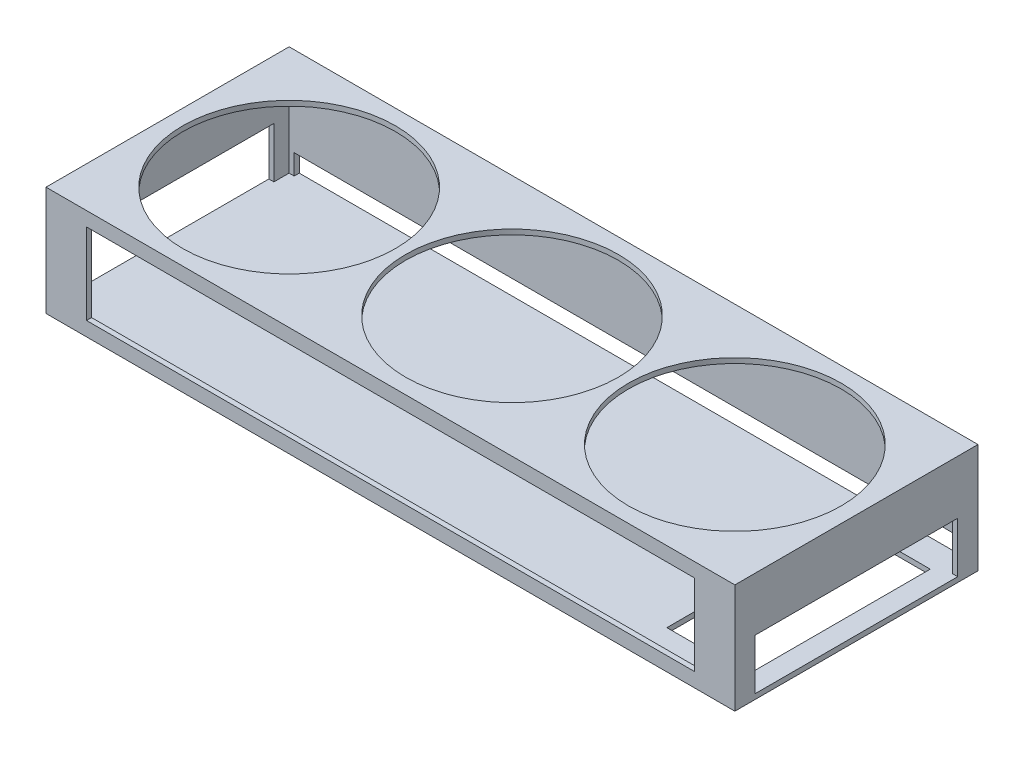
from build123d import *

# Parameters (mm, degrees)
SKETCH1_W           = 340
SKETCH1_H           = 54
BOSS_EXTRUDE1_DEPTH = 120
SHELL1_T            = 2.5
SKETCH2_R           = 52.5
CUT_EXTRUDE1_DEPTH  = 10
SKETCH3_W           = 300
SKETCH3_H           = 40
CUT_EXTRUDE2_DEPTH  = 10
SKETCH4_W           = 100
SKETCH4_H           = 25
CUT_EXTRUDE3_DEPTH  = 341
SKETCH5_W           = 40
SKETCH5_H           = 90
CUT_EXTRUDE4_DEPTH  = 10
SKETCH6_W           = 330
SKETCH6_H           = 10
CUT_EXTRUDE5_DEPTH  = 10


with BuildPart() as part:
    # Sketch1 → Boss-Extrude1 (new body)
    with BuildSketch(Plane.XY):
        Rectangle(SKETCH1_W, SKETCH1_H)
    extrude(amount=BOSS_EXTRUDE1_DEPTH)

    # Shell1 (no face opened: a closed hollow body)
    add(offset(amount=-SHELL1_T, mode=Mode.PRIVATE), mode=Mode.SUBTRACT)

    # Sketch2 → Cut-Extrude1 (cut)
    with BuildSketch(Plane(origin=(0, 27, 0), x_dir=(1, 0, 0), z_dir=(0, 1, 0))):
        with Locations((-110, -60)):
            Circle(SKETCH2_R)
        with Locations((0, -60)):
            Circle(SKETCH2_R)
        with Locations((110, -60)):
            Circle(SKETCH2_R)
    extrude(amount=-CUT_EXTRUDE1_DEPTH, mode=Mode.SUBTRACT)

    # Sketch3 → Cut-Extrude2 (cut)
    with BuildSketch(Plane.XY.offset(120)):
        Rectangle(SKETCH3_W, SKETCH3_H)
    extrude(amount=-CUT_EXTRUDE2_DEPTH, mode=Mode.SUBTRACT)

    # Sketch4 → Cut-Extrude3 (cut, through all)
    with BuildSketch(Plane(origin=(170, 0, 0), x_dir=(0, 0, -1), z_dir=(1, 0, 0))):
        with Locations((-60, -12)):
            Rectangle(SKETCH4_W, SKETCH4_H)
    extrude(amount=-CUT_EXTRUDE3_DEPTH, mode=Mode.SUBTRACT)

    # Sketch5 → Cut-Extrude4 (cut)
    with BuildSketch(Plane.XZ.offset(27)):
        with Locations((140, 58.55655344)):
            Rectangle(SKETCH5_W, SKETCH5_H)
    extrude(amount=-CUT_EXTRUDE4_DEPTH, mode=Mode.SUBTRACT)

    # Sketch6 → Cut-Extrude5 (cut)
    with BuildSketch(Plane(origin=(0, 0, 0), x_dir=(-1, 0, 0), z_dir=(0, 0, -1))):
        with Locations((0, -19.5)):
            Rectangle(SKETCH6_W, SKETCH6_H)
    extrude(amount=-CUT_EXTRUDE5_DEPTH, mode=Mode.SUBTRACT)


solid = part.part
